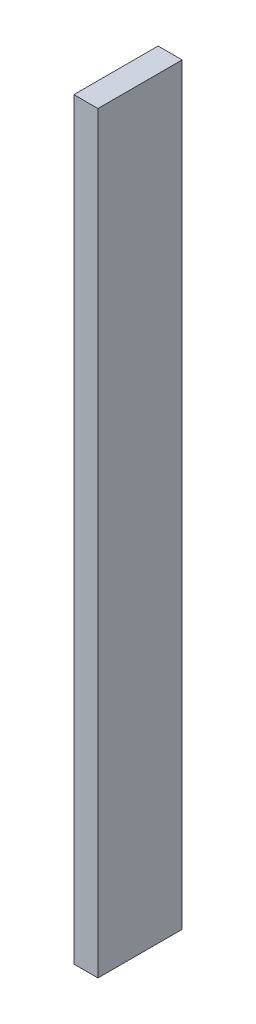
from build123d import *

# Parameters (mm, degrees)
ESQUISSE1_W        = 10
ESQUISSE1_H        = 313
BOSS_EXTRU_1_DEPTH = 35


with BuildPart() as part:
    # Esquisse1 → Boss.-Extru.1 (new body)
    with BuildSketch(Plane.XY):
        with Locations((57.65, 0.5)):
            Rectangle(ESQUISSE1_W, ESQUISSE1_H)
    extrude(amount=BOSS_EXTRU_1_DEPTH)


solid = part.part
